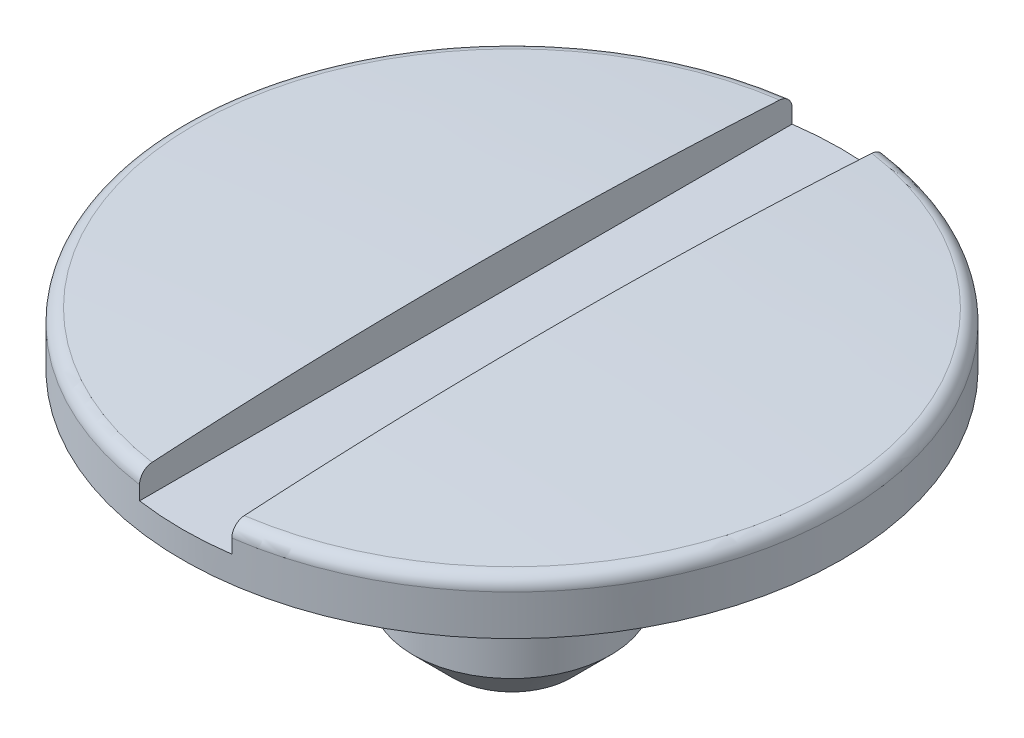
from build123d import *

# Parameters (mm, degrees)
SKETCH2_R               = 0.375
BOSS_EXTRUDE2_DEPTH     = 0.9
FILLET1_R               = 0.05
CHAMFER2_SIZE           = 0.15
CUT_EXTRUDE1_DEPTH      = 2.2500001
CUT_EXTRUDE1_DEPTH_BACK = 2.2500001


with BuildPart() as part:
    # Sketch4 → Revolve1 (revolve)
    with BuildSketch(Plane.XY):
        with BuildLine():
            Line((0, 0), (1.25, 0))
            Line((1.25, 0), (1.25, 0.2))
            ThreePointArc((1.25, 0.2), (0.625305699, 0.229323151), (0, 0.239100722))
            Line((0, 0.239100722), (0, 0))
        make_face()
    revolve(axis=Axis((0, -848.356227188, 0), (0, 1, 0)))

    # Sketch2 → Boss-Extrude2 (add)
    with BuildSketch(Plane(origin=(0, 0, 0), x_dir=(1, 0, 0), z_dir=(0, 1, 0))):
        Circle(SKETCH2_R)
    extrude(amount=-BOSS_EXTRUDE2_DEPTH)

    # Fillet1
    fillet1_edges = [part.edges().sort_by_distance(p)[0] for p in [
        (-1.25, 0.2, 0),
    ]]
    fillet(fillet1_edges, radius=FILLET1_R)

    # Chamfer2
    chamfer2_edges = [part.edges().sort_by_distance(p)[0] for p in [
        (-0.375, -0.9, 0),
    ]]
    chamfer(chamfer2_edges, length=CHAMFER2_SIZE)

    # Sketch3 → Cut-Extrude1 (cut, two sides)
    with BuildSketch(Plane.XY) as cut_extrude1_sk:
        Polygon((-0.175, 0.35), (0, 0.35), (0.175, 0.35), (0.175, 0.1), (0, 0.1), (-0.175, 0.1), align=None)
    extrude(amount=CUT_EXTRUDE1_DEPTH, mode=Mode.SUBTRACT)
    extrude(cut_extrude1_sk.sketch, amount=-CUT_EXTRUDE1_DEPTH_BACK, mode=Mode.SUBTRACT)


solid = part.part
